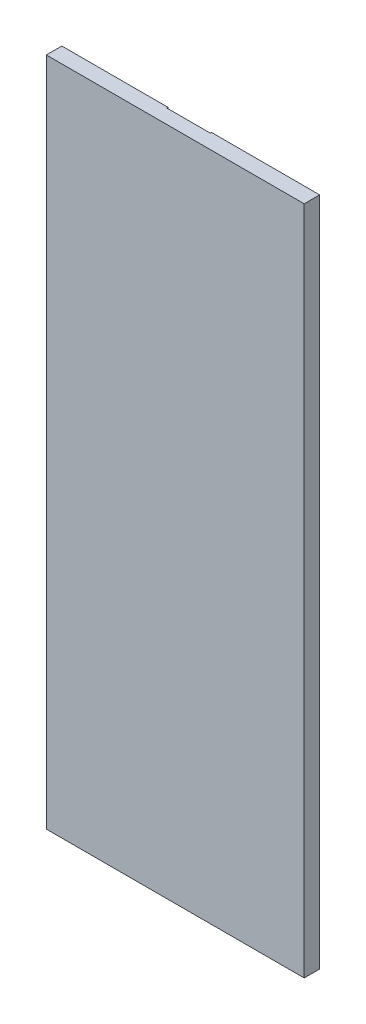
from build123d import *

# Parameters (mm, degrees)
SKETCH1_W           = 250
SKETCH1_H           = 15
BOSS_EXTRUDE1_DEPTH = 650
SKETCH3_W           = 42.3
SKETCH3_H           = 57
CUT_EXTRUDE2_DEPTH  = 1.15


with BuildPart() as part:
    # Sketch1 → Boss-Extrude1 (new body)
    with BuildSketch(Plane(origin=(0, 0, 0), x_dir=(1, 0, 0), z_dir=(0, 1, 0))):
        with Locations((125, 7.5)):
            Rectangle(SKETCH1_W, SKETCH1_H)
    extrude(amount=BOSS_EXTRUDE1_DEPTH)

    # Sketch3 → Cut-Extrude2 (cut)
    with BuildSketch(Plane(origin=(0, 0, -15), x_dir=(-1, 0, 0), z_dir=(0, 0, -1))):
        with Locations((-124, 621.5)):
            Rectangle(SKETCH3_W, SKETCH3_H)
    extrude(amount=-CUT_EXTRUDE2_DEPTH, mode=Mode.SUBTRACT)


solid = part.part
